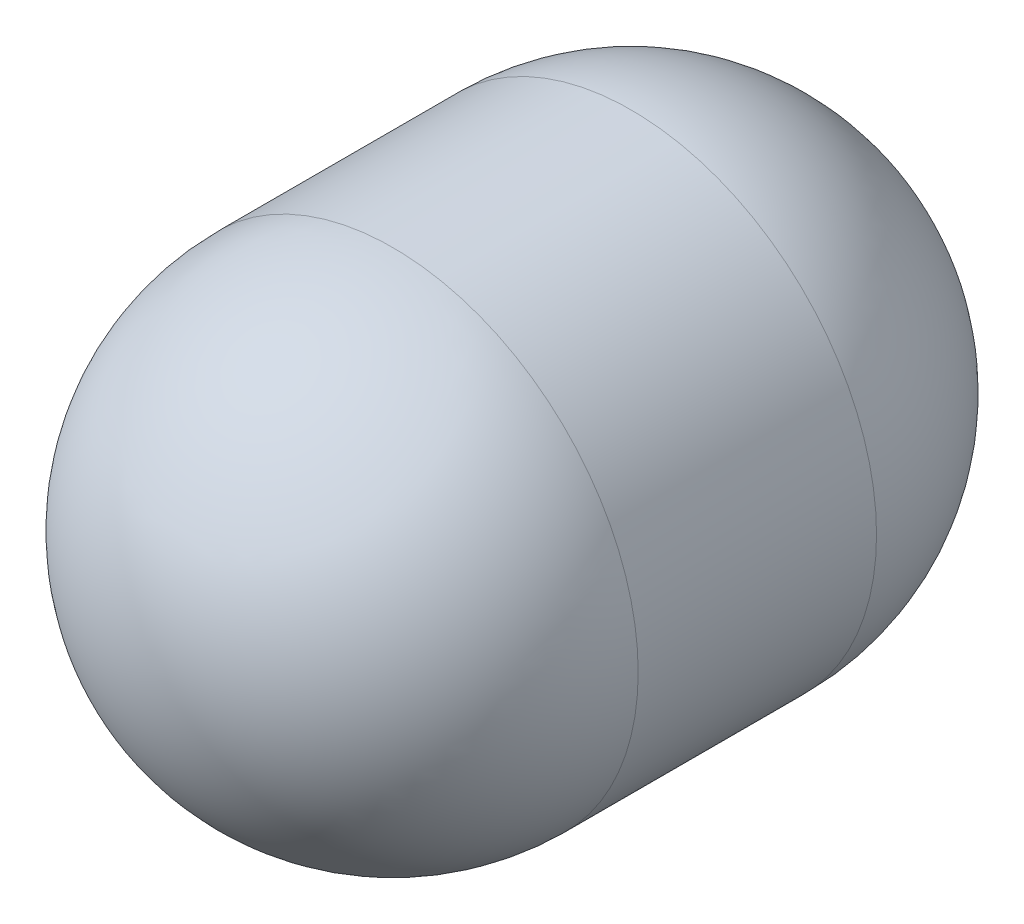
from build123d import *


with BuildPart() as part:
    # Sketch1 → Revolve1 (revolve)
    with BuildSketch(Plane(origin=(0, 0, 0), x_dir=(1, 0, 0), z_dir=(0, 1, 0))):
        with BuildLine():
            Line((55.5625, -26.9875), (55.5625, 26.9875))
            ThreePointArc((55.5625, 26.9875), (44.051337238, 60.8500323), (14.2875, 80.681622118))
            Line((14.2875, 80.681622118), (0, 80.681622118))
            Line((0, 80.681622118), (0, -82.55))
            ThreePointArc((0, -82.55), (39.28862053, -66.27612053), (55.5625, -26.9875))
        make_face()
    revolve(axis=Axis((0, 0, -80.681622118), (0, 0, 1)))


solid = part.part
